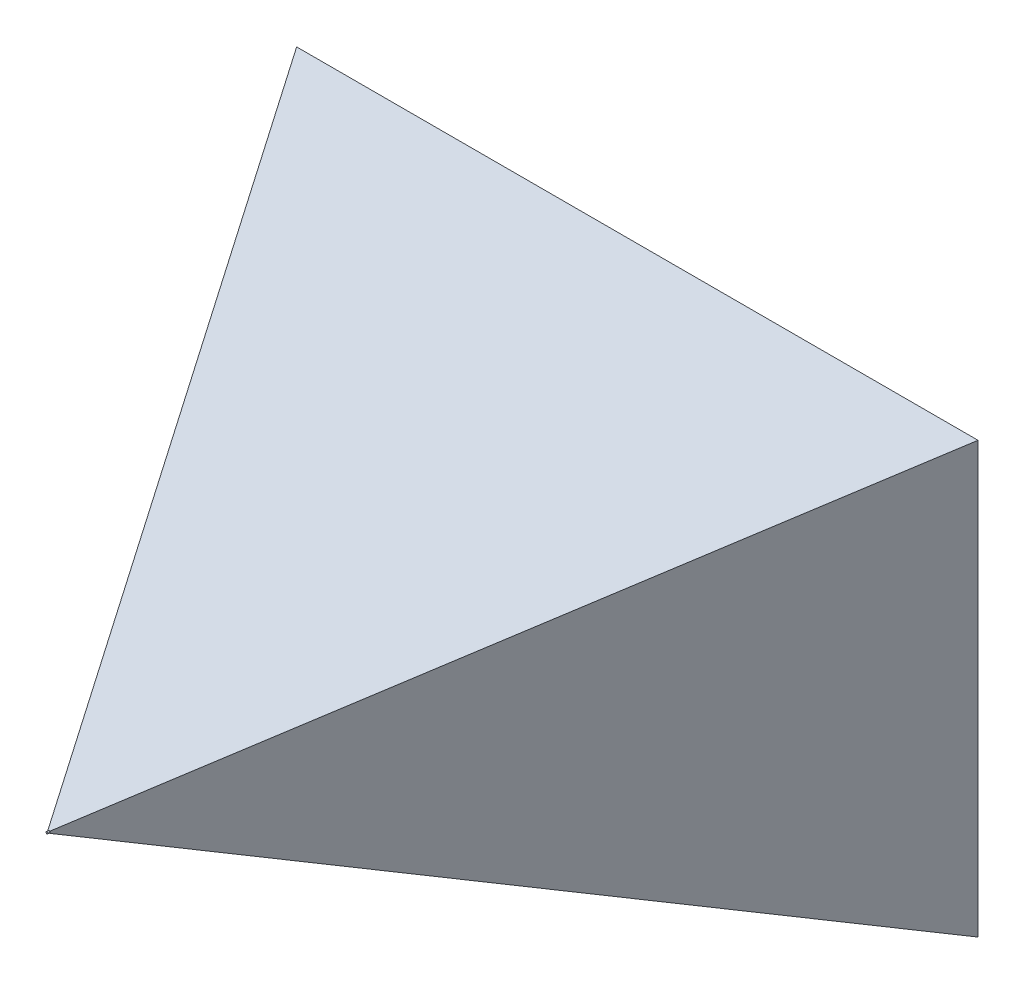
from build123d import *

# Parameters (mm, degrees)
SKETCH1_W           = 800
SKETCH1_H           = 800
BOSS_EXTRUDE1_DEPTH = 600
CUT_EXTRUDE1_DEPTH  = 801
CUT_EXTRUDE2_DEPTH  = 620.38214056
SKETCH4_R           = 1
BOSS_EXTRUDE2_DEPTH = 2


with BuildPart() as part:
    # Sketch1 → Boss-Extrude1 (new body)
    with BuildSketch(Plane.XY):
        with Locations((400, 400)):
            Rectangle(SKETCH1_W, SKETCH1_H)
    extrude(amount=BOSS_EXTRUDE1_DEPTH)

    # Sketch2 → Cut-Extrude1 (cut, through all)
    with BuildSketch(Plane(origin=(800, 0, 0), x_dir=(0, 0, -1), z_dir=(1, 0, 0))):
        Polygon((-600, 800), (-600, 401), (496.243490362, 800), align=None)
        Polygon((496.243490362, 0), (-600, 0), (-600, 399), align=None)
    extrude(amount=-CUT_EXTRUDE1_DEPTH, mode=Mode.SUBTRACT)

    # Sketch3 → Cut-Extrude2 (cut, through all)
    with BuildSketch(Plane.XZ):
        Polygon((401, 600), (800, -91.08827222), (800, 600), align=None)
        Polygon((0, 600), (0, -91.08827222), (399, 600), align=None)
    extrude(amount=-CUT_EXTRUDE2_DEPTH, mode=Mode.SUBTRACT)

    # Sketch4 → Boss-Extrude2 (add)
    with BuildSketch(Plane.XY.offset(600)):
        with Locations((400, 400)):
            Circle(SKETCH4_R)
    extrude(amount=BOSS_EXTRUDE2_DEPTH)


solid = part.part
